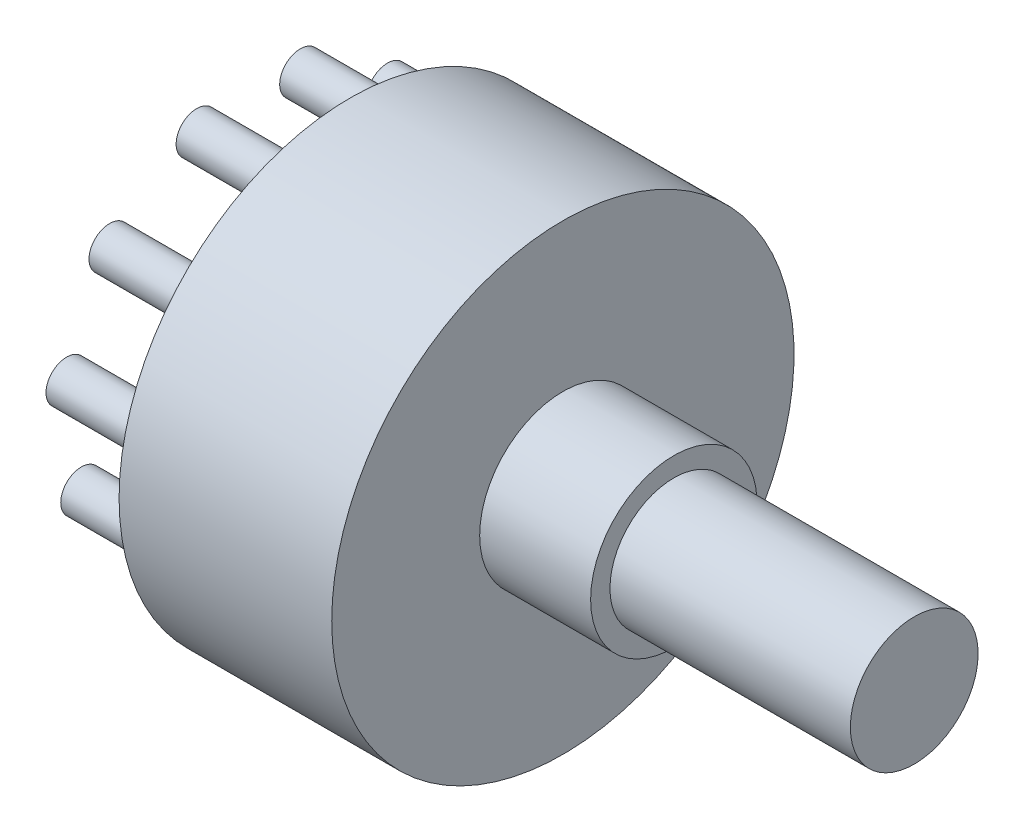
from build123d import *

# Parameters (mm, degrees)
SZKIC3_R                    = 1.114790338
DODANIE_WYCI_GNI_CIE1_DEPTH = 5.5


with BuildPart() as part:
    # Szkic1 → Obrót2 (revolve)
    with BuildSketch(Plane.XY):
        Polygon((17, 0), (7, 0), (5.5, 0), (5.5, 2.829232786), (5.5, 4.829774456), (5.5, 7.237903332), (5.5, 9.045555295), (5.5, 11.058215628), (5.5, 12.5), (36, 12.5), (36, 9.045555295), (23, 9.045555295), (23, 8), (17, 8), align=None)
    revolve(axis=Axis((5.5, 12.5, 0), (1, 0, 0)))

    # Szkic3 → Dodanie-wyciągnięcie1 (add)
    with BuildSketch(Plane.ZY.offset(-5.5)):
        with Locations((-5.372694462, 4.139924233)):
            Circle(SZKIC3_R)
        with Locations((5.372694462, 4.139924233)):
            Circle(SZKIC3_R)
        with Locations((9.039596394, 8.371754652)):
            Circle(SZKIC3_R)
        with Locations((9.836490341, 13.9142738)):
            Circle(SZKIC3_R)
        with Locations((7.510368107, 19.00777101)):
            Circle(SZKIC3_R)
        with Locations((-2.799757064, 22.035096905)):
            Circle(SZKIC3_R)
        with Locations((-7.510368107, 19.00777101)):
            Circle(SZKIC3_R)
        with Locations((-9.836490341, 13.9142738)):
            Circle(SZKIC3_R)
        with Locations((-9.039596394, 8.371754652)):
            Circle(SZKIC3_R)
        with Locations((0, 2.5623588)):
            Circle(SZKIC3_R)
        with Locations((2.799757064, 22.035096905)):
            Circle(SZKIC3_R)
    extrude(amount=DODANIE_WYCI_GNI_CIE1_DEPTH)


solid = part.part
